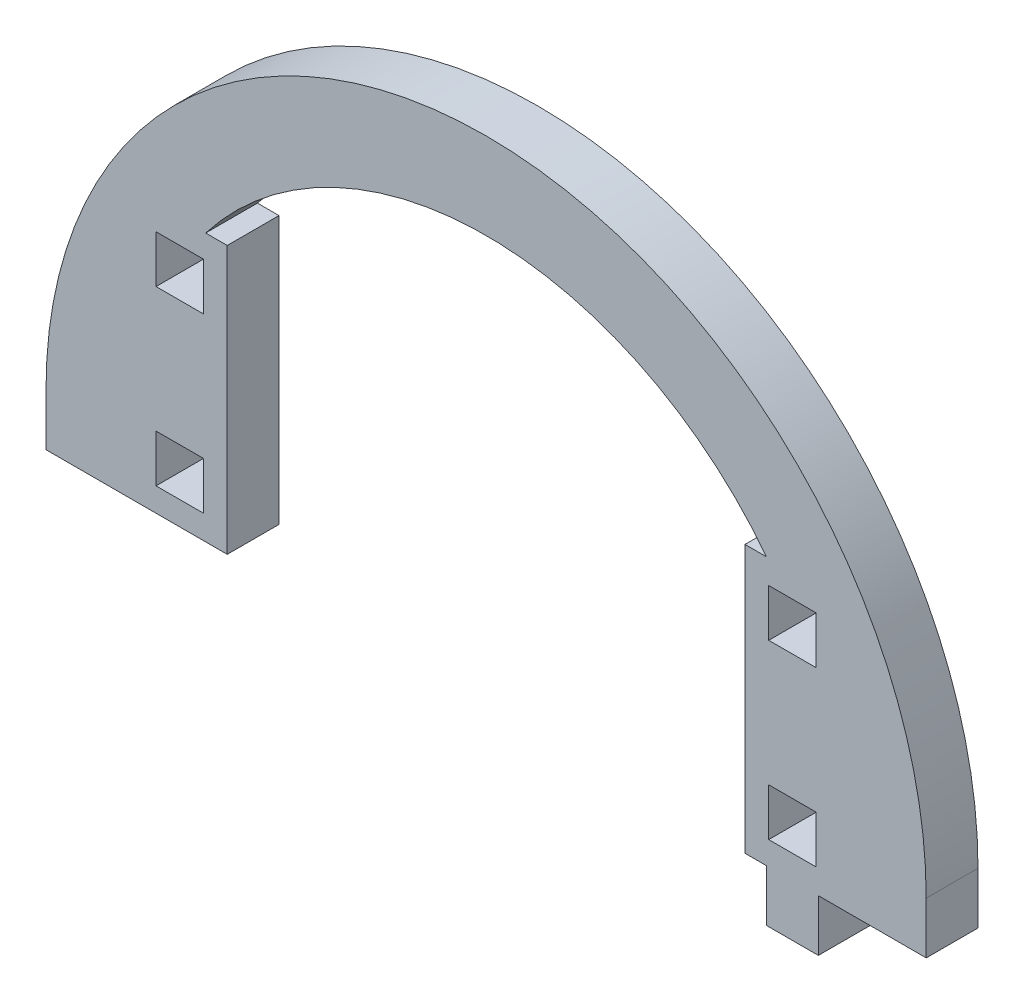
from build123d import *

# Parameters (mm, degrees)
MODEL_W             = 5.5
MODEL_H             = 5.5
BOSS_EXTRUDE1_DEPTH = 6


with BuildPart() as part:
    # Model → Boss-Extrude1 (new body)
    with BuildSketch(Plane.XY):
        with BuildLine():
            Line((3357.032259061, 1716.994350869), (3357.032259061, 1710.994350869))
            Line((3357.032259061, 1710.994350869), (3367.032259061, 1710.994350869))
            Line((3367.032259061, 1710.994350869), (3378.032259061, 1710.994350869))
            Line((3378.032259061, 1710.994350869), (3378.032259061, 1741.994350869))
            Line((3378.032259061, 1741.994350869), (3375.536105442, 1741.994350869))
            ThreePointArc((3375.536105442, 1741.994350869), (3408.032259061, 1757.994350869), (3440.528412679, 1741.994350869))
            Line((3440.528412679, 1741.994350869), (3438.032259061, 1741.994350869))
            Line((3438.032259061, 1741.994350869), (3438.032259061, 1710.994350869))
            Line((3438.032259061, 1710.994350869), (3440.532259061, 1710.994350869))
            Line((3440.532259061, 1710.994350869), (3440.532259061, 1704.994350869))
            Line((3440.532259061, 1704.994350869), (3446.532259061, 1704.994350869))
            Line((3446.532259061, 1704.994350869), (3446.532259061, 1710.994350869))
            Line((3446.532259061, 1710.994350869), (3459.032259061, 1710.994350869))
            Line((3459.032259061, 1710.994350869), (3459.032259061, 1716.994350869))
            ThreePointArc((3459.032259061, 1716.994350869), (3408.032259061, 1767.994350869), (3357.032259061, 1716.994350869))
        make_face()
        with Locations((3443.532259061, 1716.494350869)):
            Rectangle(MODEL_W, MODEL_H, mode=Mode.SUBTRACT)
        with Locations((3443.532259061, 1736.494350869)):
            Rectangle(MODEL_W, MODEL_H, mode=Mode.SUBTRACT)
        with Locations((3372.532259061, 1716.494350869)):
            Rectangle(MODEL_W, MODEL_H, mode=Mode.SUBTRACT)
        with Locations((3372.532259061, 1736.494350869)):
            Rectangle(MODEL_W, MODEL_H, mode=Mode.SUBTRACT)
    extrude(amount=BOSS_EXTRUDE1_DEPTH)


solid = part.part
